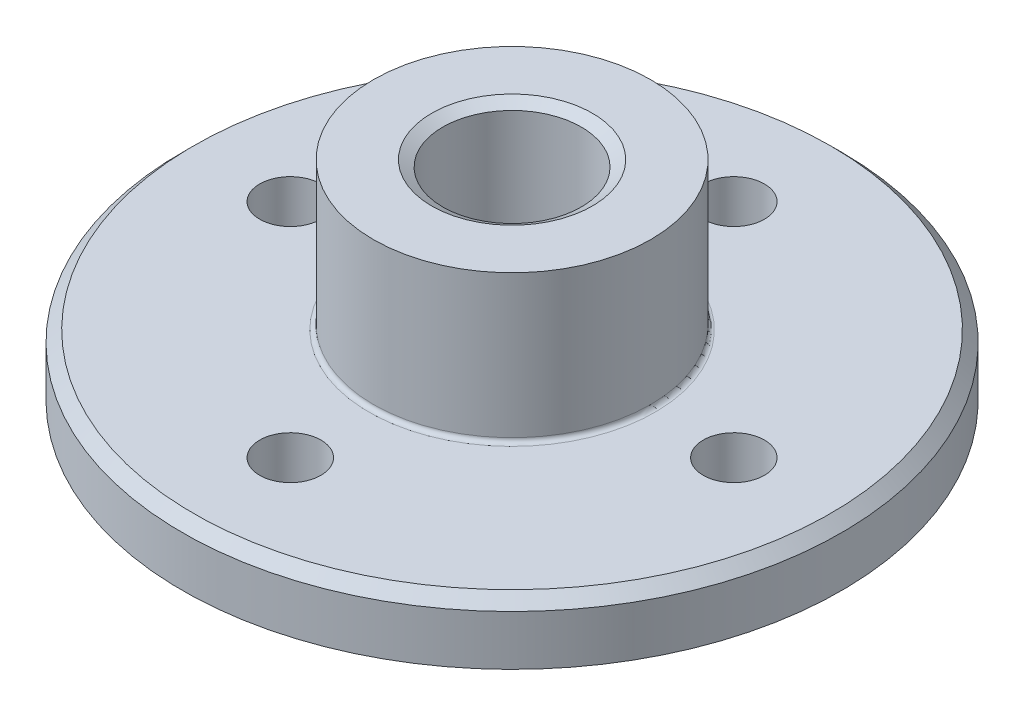
from build123d import *

# Parameters (mm, degrees)
SKETCH1_W                          = 8.4328
SKETCH1_H                          = 7.9375
F_5_16_24_TAPPED_HOLE1_D           = 7.9375
F_5_16_24_TAPPED_HOLE1_DEPTH       = 8.4328
F_5_16_24_TAPPED_HOLE1_CSINK_D     = 9.2075
F_5_16_24_TAPPED_HOLE1_CSINK_ANGLE = 120
SKETCH4_W                          = 18.873319712
SKETCH4_H                          = 3.5052
FILLET1_R                          = 0.254
F_6_32_TAPPED_HOLE1_D              = 3.5052
F_6_32_TAPPED_HOLE1_DEPTH          = 3.5062
CIRPATTERN1_COUNT                  = 4
CHAMFER1_SIZE                      = 0.635


with BuildPart() as part:
    # Sketch1 → Base-Revolve (revolve)
    with BuildSketch(Plane(origin=(0, 0, 0), x_dir=(0, 1, 0), z_dir=(0, 0, 1)), mode=Mode.PRIVATE) as base_revolve_sk:
        with Locations((-1.2446, 3.96875)):
            Rectangle(SKETCH1_W, SKETCH1_H)
    revolve(base_revolve_sk.sketch.rotate(Axis((0, -5.461, 0), (0, 1, 0)), 180), axis=Axis((0, -5.461, 0), (0, 1, 0)))  # turned: the seam where the file's is

    # 5_16-24 Tapped Hole1
    with Locations(Plane(origin=(0, 2.9718, 0), x_dir=(-1, 0, 0), z_dir=(0, 1, 0))):
        with Locations((0, 0)):
            CounterSinkHole(F_5_16_24_TAPPED_HOLE1_D / 2, F_5_16_24_TAPPED_HOLE1_CSINK_D / 2, depth=F_5_16_24_TAPPED_HOLE1_DEPTH, counter_sink_angle=F_5_16_24_TAPPED_HOLE1_CSINK_ANGLE)

    # Sketch4 → Revolve1 (revolve)
    with BuildSketch(Plane.XY, mode=Mode.PRIVATE) as revolve1_sk:
        with Locations((-9.436659856, -7.2136)):
            Rectangle(SKETCH4_W, SKETCH4_H)
    revolve(revolve1_sk.sketch.rotate(Axis((0, -29.193959905, 0), (0, 1, 0)), 180), axis=Axis((0, -29.193959905, 0), (0, 1, 0)))  # turned: the seam where the file's is

    # Sketch5 → 5_16-18 Tapped Hole2 (revolve, cut)
    with BuildSketch(Plane(origin=(0, -5.461, 0), x_dir=(0, 0, 1), z_dir=(1, 0, 0))):
        Polygon((0, 0), (0, 3.5052), (4.60375, 3.5052), (3.96875, 3.138582579), (3.96875, 0), align=None)
    revolve(axis=Axis((0, 0.889, 0), (0, -1, 0)), mode=Mode.SUBTRACT)

    # Fillet1
    fillet1_edges = [part.edges().sort_by_distance(p)[0] for p in [
        (-7.9375, -5.461, 0),
    ]]
    fillet(fillet1_edges, radius=FILLET1_R)

    # 6-32 Tapped Hole1
    with Locations(Plane.XZ.offset(8.9662)):
        with Locations((0, 12.7)):
            f_6_32_tapped_hole1 = Hole(F_6_32_TAPPED_HOLE1_D / 2, depth=F_6_32_TAPPED_HOLE1_DEPTH)

    # CirPattern1: 6-32 Tapped Hole1 ×4 about axis
    cirpattern1_axis = Axis((0, 0, 0), (0, 1, 0))
    for i in range(1, CIRPATTERN1_COUNT):
        add(f_6_32_tapped_hole1.rotate(cirpattern1_axis, i * 360 / CIRPATTERN1_COUNT), mode=Mode.SUBTRACT)

    # Chamfer1
    chamfer1_edges = [part.edges().sort_by_distance(p)[0] for p in [
        (-18.873319712, -5.461, 0),
    ]]
    chamfer(chamfer1_edges, length=CHAMFER1_SIZE)


solid = part.part
